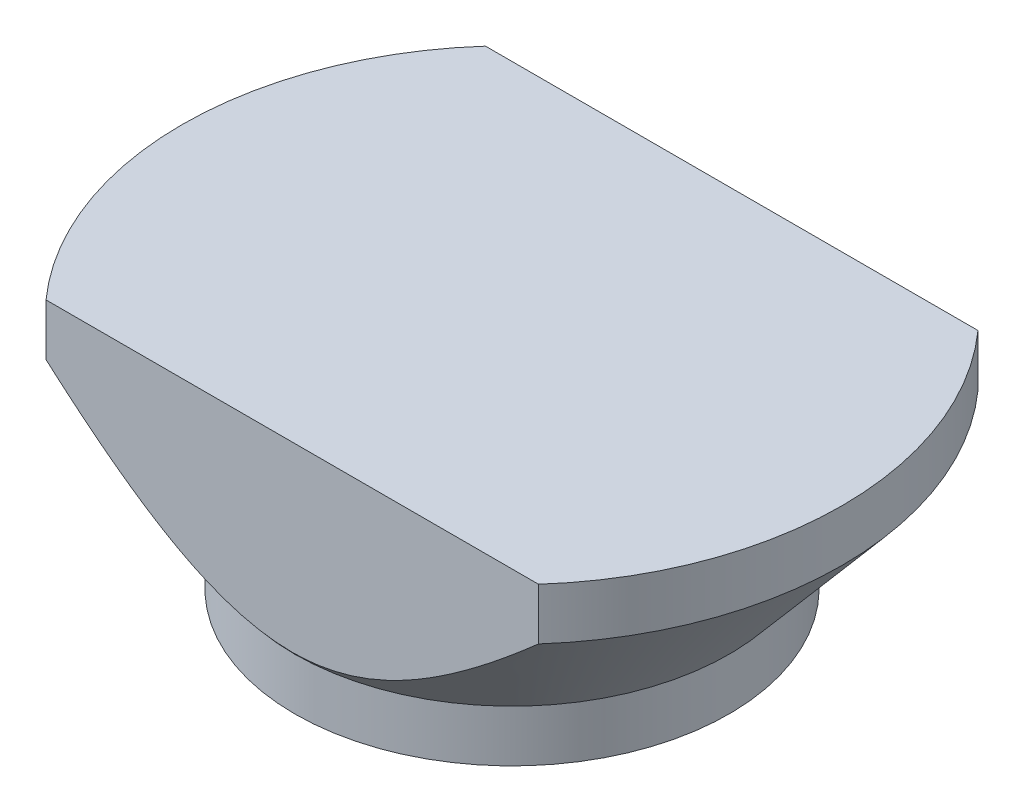
from build123d import *

# Parameters (mm, degrees)
SKETCH2_W          = 47.62425259
SKETCH2_H          = 10.665197925
CUT_EXTRUDE2_DEPTH = 23.9


with BuildPart() as part:
    # Sketch1 → Revolve1 (revolve)
    with BuildSketch(Plane.XY):
        Polygon((0, 0), (-21, 0), (-21, 5), (-31.91519793, 17.9), (-31.91519793, 22.9), (0, 22.9), align=None)
    revolve(axis=Axis((0, 22.9, 0), (0, -1, 0)))

    # Sketch2 → Cut-Extrude2 (cut, through all)
    with BuildSketch(Plane(origin=(0, 0, 0), x_dir=(1, 0, 0), z_dir=(0, 1, 0))):
        with Locations((0, 26.582598968)):
            Rectangle(SKETCH2_W, SKETCH2_H)
        with Locations((0, -26.582598968)):
            Rectangle(SKETCH2_W, SKETCH2_H)
    extrude(amount=CUT_EXTRUDE2_DEPTH, mode=Mode.SUBTRACT)


solid = part.part
